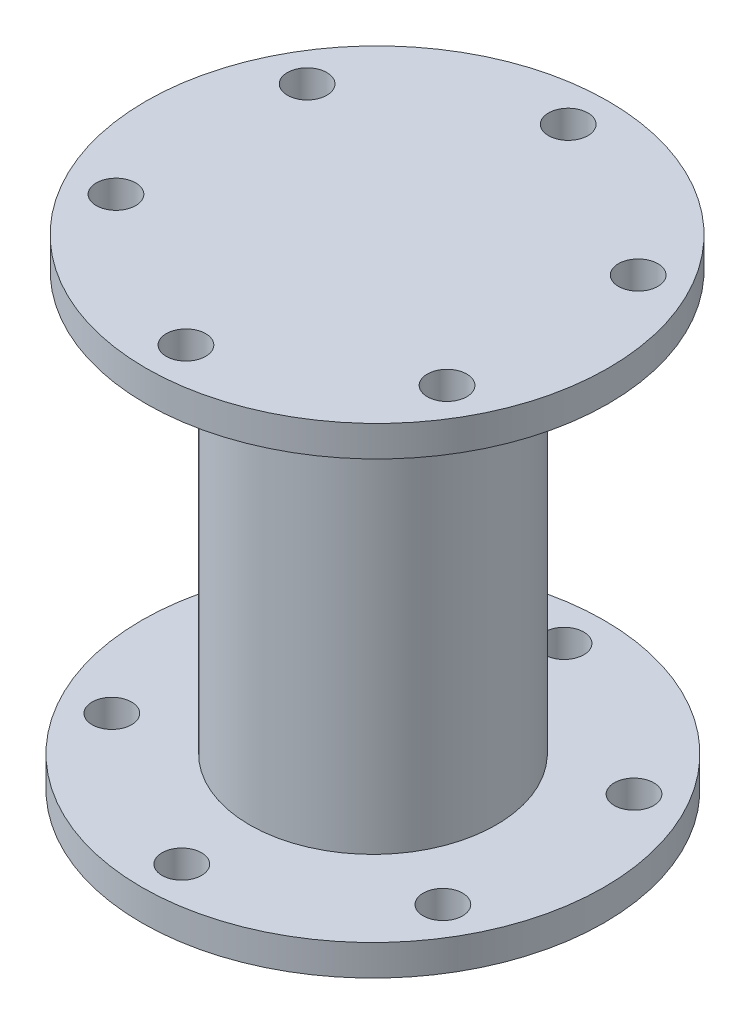
from build123d import *

# Parameters (mm, degrees)
SKETCH1_R           = 37.5
SKETCH1_R_2         = 3.2
BOSS_EXTRUDE1_DEPTH = 5
SKETCH2_R           = 20
BOSS_EXTRUDE2_DEPTH = 68
SKETCH5_R           = 37.5
SKETCH5_R_2         = 3.2
BOSS_EXTRUDE3_DEPTH = 5


with BuildPart() as part:
    # Sketch1 → Boss-Extrude1 (new body)
    with BuildSketch(Plane(origin=(0, 0, 0), x_dir=(1, 0, 0), z_dir=(0, 1, 0))):
        Circle(SKETCH1_R)
        with Locations((0, 31)):
            Circle(SKETCH1_R_2, mode=Mode.SUBTRACT)
        with Locations((26.846787517, 15.5)):
            Circle(SKETCH1_R_2, mode=Mode.SUBTRACT)
        with Locations((26.846787517, -15.5)):
            Circle(SKETCH1_R_2, mode=Mode.SUBTRACT)
        with Locations((0, -31)):
            Circle(SKETCH1_R_2, mode=Mode.SUBTRACT)
        with Locations((-26.846787517, -15.5)):
            Circle(SKETCH1_R_2, mode=Mode.SUBTRACT)
        with Locations((-26.846787517, 15.5)):
            Circle(SKETCH1_R_2, mode=Mode.SUBTRACT)
    extrude(amount=BOSS_EXTRUDE1_DEPTH)

    # Sketch2 → Boss-Extrude2 (add)
    with BuildSketch(Plane(origin=(0, 5, 0), x_dir=(1, 0, 0), z_dir=(0, 1, 0))):
        Circle(SKETCH2_R)
    extrude(amount=BOSS_EXTRUDE2_DEPTH)

    # Sketch5 → Boss-Extrude3 (add)
    with BuildSketch(Plane(origin=(0, 73, 0), x_dir=(1, 0, 0), z_dir=(0, 1, 0))):
        with Locations((0.421553843, 0.250555935)):
            Circle(SKETCH5_R)
        with Locations((0.421553843, 31.250555935)):
            Circle(SKETCH5_R_2, mode=Mode.SUBTRACT)
        with Locations((27.268341361, 15.750555935)):
            Circle(SKETCH5_R_2, mode=Mode.SUBTRACT)
        with Locations((27.268341361, -15.249444065)):
            Circle(SKETCH5_R_2, mode=Mode.SUBTRACT)
        with Locations((0.421553843, -30.749444065)):
            Circle(SKETCH5_R_2, mode=Mode.SUBTRACT)
        with Locations((-26.425233674, -15.249444065)):
            Circle(SKETCH5_R_2, mode=Mode.SUBTRACT)
        with Locations((-26.425233674, 15.750555935)):
            Circle(SKETCH5_R_2, mode=Mode.SUBTRACT)
    extrude(amount=BOSS_EXTRUDE3_DEPTH)


solid = part.part
